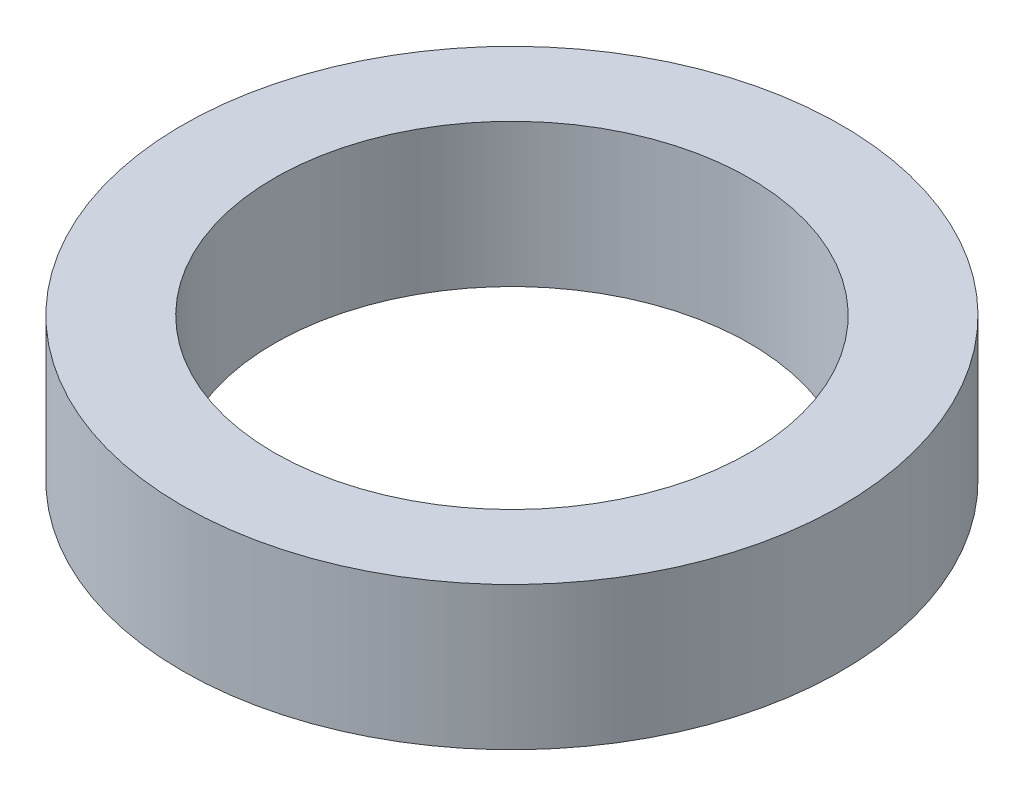
from build123d import *

# Parameters (mm, degrees)
SKETCH1_R           = 3.5
SKETCH1_R_2         = 2.525
BOSS_EXTRUDE1_DEPTH = 1.52


with BuildPart() as part:
    # Sketch1 → Boss-Extrude1 (new body)
    with BuildSketch(Plane(origin=(0, 0, 0), x_dir=(1, 0, 0), z_dir=(0, 1, 0))):
        Circle(SKETCH1_R)
        Circle(SKETCH1_R_2, mode=Mode.SUBTRACT)
    extrude(amount=BOSS_EXTRUDE1_DEPTH)


solid = part.part
